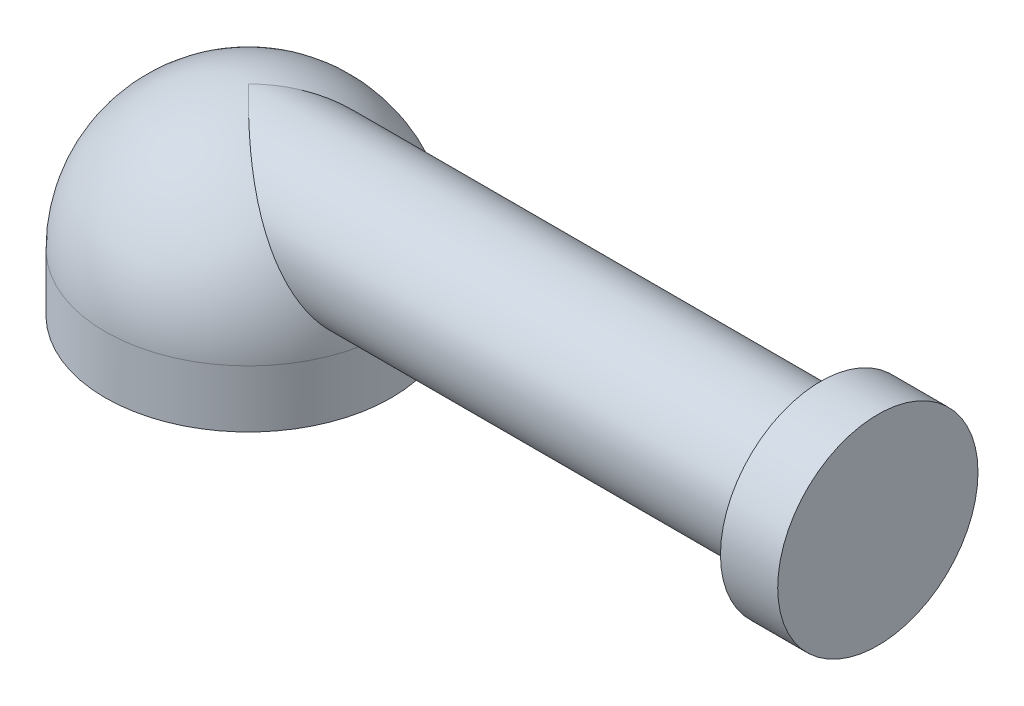
from build123d import *

# Parameters (mm, degrees)
SKETCH_1_R      = 2.5
SKETCH_1_R_2    = 2
EXTRUDE_1_DEPTH = 1
SKETCH_3_R      = 1.25
EXTRUDE_2_DEPTH = 10
SKETCH_4_R      = 1.75
EXTRUDE_3_DEPTH = 1


with BuildPart() as part:
    # 草图1 → 凸台-拉伸1 (new body)
    with BuildSketch(Plane(origin=(0, 0, 0), x_dir=(1, 0, 0), z_dir=(0, 1, 0))):
        Circle(SKETCH_1_R)
        Circle(SKETCH_1_R_2, mode=Mode.SUBTRACT)
    extrude(amount=EXTRUDE_1_DEPTH)

    # 草图2 → 旋转1 (revolve)
    with BuildSketch(Plane.XY):
        with BuildLine():
            Line((0, 3.5), (0, 1))
            Line((0, 1), (2.5, 1))
            ThreePointArc((2.5, 1), (1.767766953, 2.767766953), (0, 3.5))
        make_face()
    revolve(axis=Axis((0, 1, 0), (0, 1, 0)))

    # 草图3 → 凸台-拉伸2 (add)
    with BuildSketch(Plane(origin=(0, 0, 0), x_dir=(0, 0, -1), z_dir=(1, 0, 0))):
        with Locations((0, 2.25)):
            Circle(SKETCH_3_R)
    extrude(amount=EXTRUDE_2_DEPTH)

    # 草图4 → 凸台-拉伸3 (add)
    with BuildSketch(Plane(origin=(10, 0, 0), x_dir=(0, 0, -1), z_dir=(1, 0, 0))):
        with Locations((0, 2.25)):
            Circle(SKETCH_4_R)
    extrude(amount=EXTRUDE_3_DEPTH)


solid = part.part
